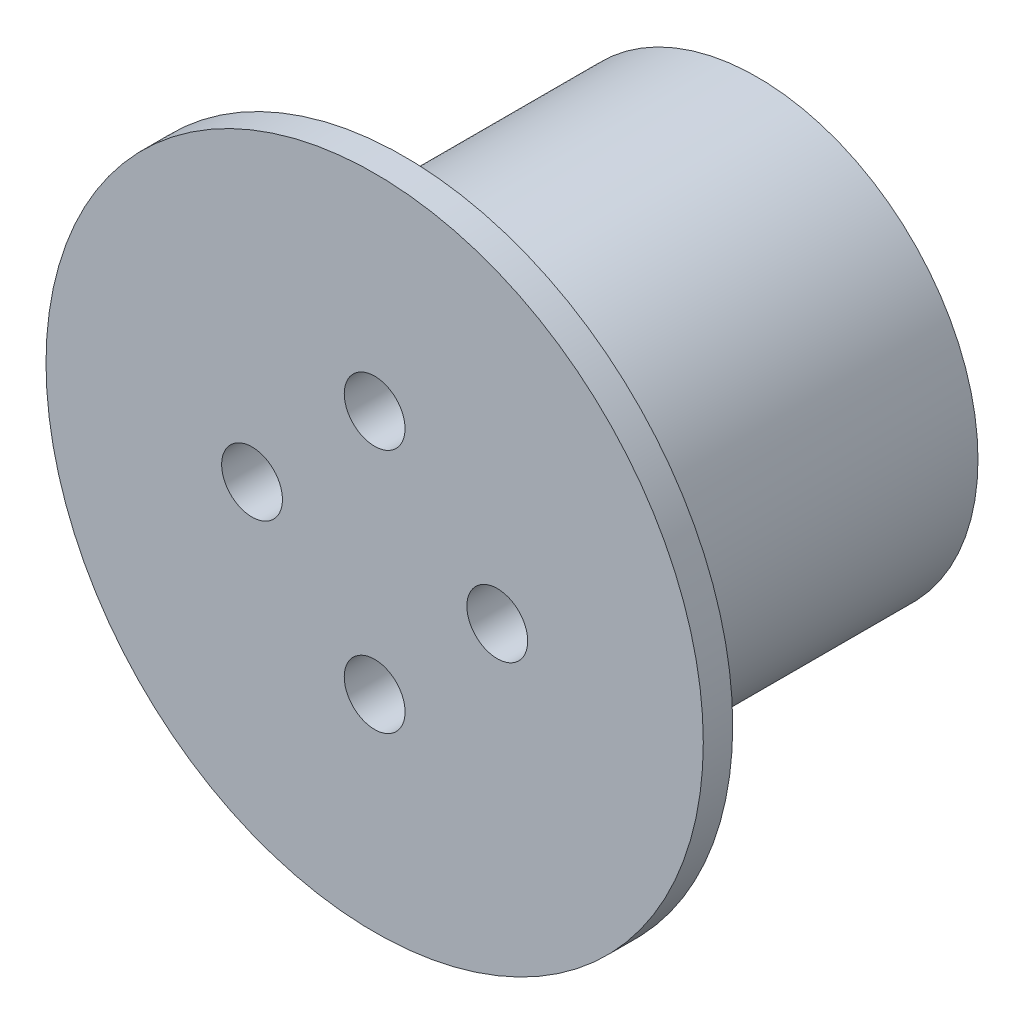
from build123d import *

# Parameters (mm, degrees)
SKETCH1_R               = 22.5
BOSS_EXTRUDE1_DEPTH     = 36
SKETCH1_3_R             = 2.25
CUT_EXTRUDE1_DEPTH      = 10
SKETCH2_R               = 33.5
BOSS_EXTRUDE2_DEPTH     = 3
CUT_EXTRUDE2_DEPTH      = 10
CUT_EXTRUDE2_DEPTH_BACK = 3
SKETCH3_R               = 3.1


with BuildPart() as part:
    # Sketch1 → Boss-Extrude1 (new body)
    with BuildSketch(Plane.XY):
        Circle(SKETCH1_R)
    extrude(amount=BOSS_EXTRUDE1_DEPTH)

    # Sketch1_3 → Cut-Extrude1 (cut)
    with BuildSketch(Plane.XY):
        with Locations((0, 15)):
            Circle(SKETCH1_3_R)
        with Locations((15, 0)):
            Circle(SKETCH1_3_R)
        with Locations((0, -15)):
            Circle(SKETCH1_3_R)
        with Locations((-15, 0)):
            Circle(SKETCH1_3_R)
    extrude(amount=CUT_EXTRUDE1_DEPTH, mode=Mode.SUBTRACT)

    # Sketch2 → Boss-Extrude2 (add)
    with BuildSketch(Plane.XY.offset(36)):
        Circle(SKETCH2_R)
    extrude(amount=BOSS_EXTRUDE2_DEPTH)

    # Sketch3 → Cut-Extrude2 (cut, two sides: drawn at the far end of the back side and taken through both)
    with BuildSketch(Plane(origin=(0, 0, 36), x_dir=(-1, 0, 0), z_dir=(0, 0, -1)).offset(-CUT_EXTRUDE2_DEPTH_BACK)):
        with Locations((0, 12.5)):
            Circle(SKETCH3_R)
        with Locations((12.5, 0)):
            Circle(SKETCH3_R)
        with Locations((0, -12.5)):
            Circle(SKETCH3_R)
        with Locations((-12.5, 0)):
            Circle(SKETCH3_R)
    extrude(amount=CUT_EXTRUDE2_DEPTH + CUT_EXTRUDE2_DEPTH_BACK, mode=Mode.SUBTRACT)


solid = part.part
